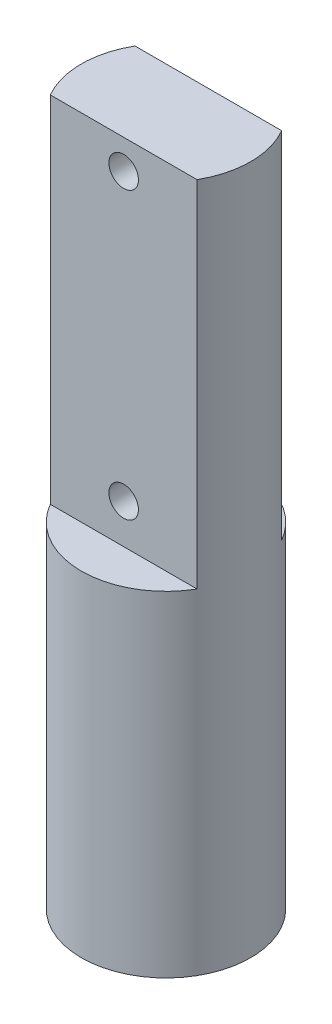
from build123d import *

# Parameters (mm, degrees)
SKETCH2_R           = 4.3
BOSS_EXTRUDE2_DEPTH = 35
CUT_EXTRUDE2_DEPTH  = 18
SKETCH6_R           = 0.75
CUT_EXTRUDE3_DEPTH  = 10
SKETCH8_R           = 0.75
CUT_EXTRUDE5_DEPTH  = 5.3
SKETCH9_R           = 0.75
CUT_EXTRUDE6_DEPTH  = 10


with BuildPart() as part:
    # Sketch2 → Boss-Extrude2 (new body)
    with BuildSketch(Plane(origin=(0, 0, 0), x_dir=(1, 0, 0), z_dir=(0, 1, 0))):
        Circle(SKETCH2_R)
    extrude(amount=BOSS_EXTRUDE2_DEPTH)

    # Sketch4 → Cut-Extrude2 (cut)
    with BuildSketch(Plane(origin=(0, 35, 0), x_dir=(1, 0, 0), z_dir=(0, 1, 0))):
        with BuildLine():
            Line((0, 2.15), (-3.723909236, 2.15))
            ThreePointArc((-3.723909236, 2.15), (0, 4.3), (3.723909236, 2.15))
            Line((3.723909236, 2.15), (0, 2.15))
        make_face()
        with BuildLine():
            Line((0, -2.15), (-3.723909236, -2.15))
            ThreePointArc((-3.723909236, -2.15), (0, -4.3), (3.723909236, -2.15))
            Line((3.723909236, -2.15), (0, -2.15))
        make_face()
    extrude(amount=-CUT_EXTRUDE2_DEPTH, mode=Mode.SUBTRACT)

    # Sketch6 → Cut-Extrude3 (cut)
    with BuildSketch(Plane.XY.offset(2.15)):
        with Locations((0, 19)):
            Circle(SKETCH6_R)
    extrude(amount=-CUT_EXTRUDE3_DEPTH, mode=Mode.SUBTRACT)

    # Sketch8 → Cut-Extrude5 (cut, through all)
    with BuildSketch(Plane(origin=(0, 0, 0), x_dir=(0, 0, -1), z_dir=(1, 0, 0))):
        with Locations((0, 1)):
            Circle(SKETCH8_R)
    extrude(amount=-CUT_EXTRUDE5_DEPTH, mode=Mode.SUBTRACT)

    # Sketch9 → Cut-Extrude6 (cut)
    with BuildSketch(Plane.XY.offset(2.15)):
        with Locations((0, 33.5)):
            Circle(SKETCH9_R)
    extrude(amount=-CUT_EXTRUDE6_DEPTH, mode=Mode.SUBTRACT)


solid = part.part
